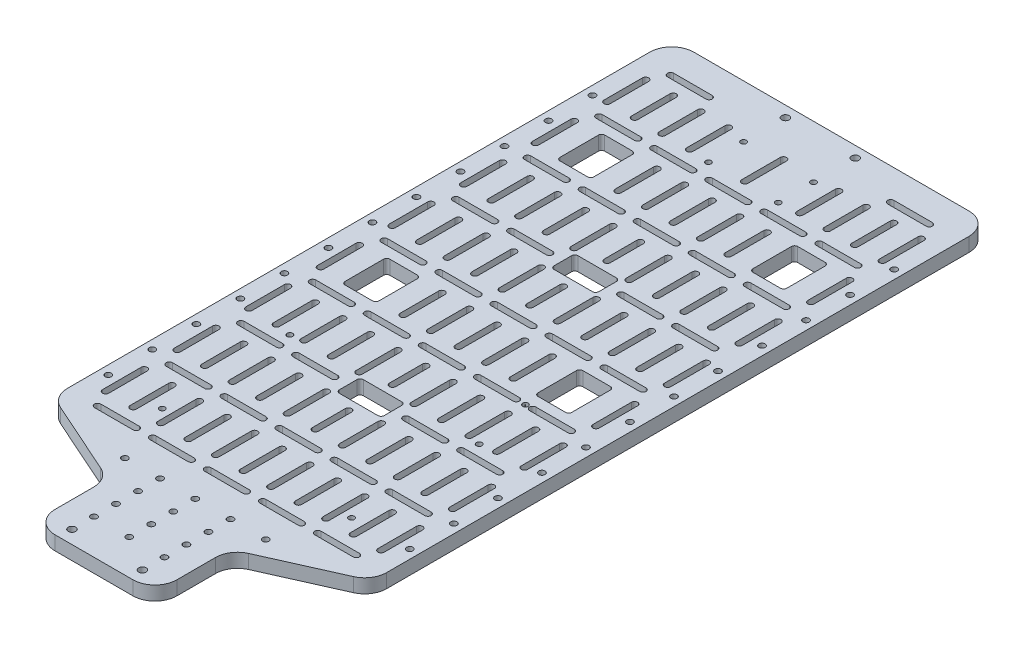
from build123d import *

# Parameters (mm, degrees)
SKETCH1_W           = 145
SKETCH1_H           = 335
BOSS_EXTRUDE1_DEPTH = 6.35
SKETCH2_R           = 1.7
SKETCH2_R_2         = 1.4224
SKETCH2_R_3         = 1.27
SKETCH2_R_4         = 0.056
CUT_EXTRUDE1_DEPTH  = 7.35
FILLET1_R           = 10


with BuildPart() as part:
    # Sketch1 → Boss-Extrude1 (new body)
    with BuildSketch(Plane(origin=(0, 0, 0), x_dir=(1, 0, 0), z_dir=(0, 1, 0))):
        with Locations((0, -167.5)):
            Rectangle(SKETCH1_W, SKETCH1_H)
    extrude(amount=BOSS_EXTRUDE1_DEPTH)

    # Sketch2 → Cut-Extrude1 (cut, through all)
    with BuildSketch(Plane(origin=(0, 6.35, 0), x_dir=(1, 0, 0), z_dir=(0, 1, 0))):
        with Locations((-15.875, -5)):
            Circle(SKETCH2_R)
        with Locations((-16, -329)):
            Circle(SKETCH2_R)
        with Locations((-68.497571427, -240)):
            Circle(SKETCH2_R_2)
        with Locations((68.497571427, -240)):
            Circle(SKETCH2_R_2)
        with Locations((-68.497571427, -220)):
            Circle(SKETCH2_R_2)
        with Locations((-68.497571427, -200)):
            Circle(SKETCH2_R_2)
        with Locations((-68.497571427, -180)):
            Circle(SKETCH2_R_2)
        with Locations((-68.497571427, -160)):
            Circle(SKETCH2_R_2)
        with Locations((-68.497571427, -140)):
            Circle(SKETCH2_R_2)
        with Locations((-68.497571427, -120)):
            Circle(SKETCH2_R_2)
        with Locations((-68.497571427, -100)):
            Circle(SKETCH2_R_2)
        with Locations((-68.497571427, -80)):
            Circle(SKETCH2_R_2)
        with Locations((-68.497571427, -60)):
            Circle(SKETCH2_R_2)
        with Locations((-68.497571427, -40)):
            Circle(SKETCH2_R_2)
        with Locations((-68.497571427, -260)):
            Circle(SKETCH2_R_2)
        with Locations((68.497571427, -40)):
            Circle(SKETCH2_R_2)
        with Locations((68.497571427, -60)):
            Circle(SKETCH2_R_2)
        with Locations((68.497571427, -80)):
            Circle(SKETCH2_R_2)
        with Locations((68.497571427, -100)):
            Circle(SKETCH2_R_2)
        with Locations((68.497571427, -120)):
            Circle(SKETCH2_R_2)
        with Locations((68.497571427, -140)):
            Circle(SKETCH2_R_2)
        with Locations((68.497571427, -160)):
            Circle(SKETCH2_R_2)
        with Locations((68.497571427, -180)):
            Circle(SKETCH2_R_2)
        with Locations((68.497571427, -200)):
            Circle(SKETCH2_R_2)
        with Locations((68.497571427, -220)):
            Circle(SKETCH2_R_2)
        with Locations((68.497571427, -260)):
            Circle(SKETCH2_R_2)
        with Locations((16, -329)):
            Circle(SKETCH2_R)
        with Locations((15.875, -5)):
            Circle(SKETCH2_R)
        with Locations((-15.875, -40)):
            Circle(SKETCH2_R_3)
        with Locations((-15.875, -24)):
            Circle(SKETCH2_R_3)
        with Locations((15.875, -40)):
            Circle(SKETCH2_R_3)
        with Locations((15.875, -24)):
            Circle(SKETCH2_R_3)
        with Locations((-43, -261)):
            Circle(SKETCH2_R_3)
        with Locations((-43, -203)):
            Circle(SKETCH2_R_3)
        with Locations((43, -261)):
            Circle(SKETCH2_R_3)
        with Locations((43, -203)):
            Circle(SKETCH2_R_3)
        with Locations((0, -319)):
            Circle(SKETCH2_R_2)
        with Locations((16, -319)):
            Circle(SKETCH2_R_2)
        with Locations((-16, -319)):
            Circle(SKETCH2_R_2)
        with Locations((-16, -309)):
            Circle(SKETCH2_R_2)
        with Locations((0, -309)):
            Circle(SKETCH2_R_2)
        with Locations((16, -309)):
            Circle(SKETCH2_R_2)
        with Locations((-16, -299)):
            Circle(SKETCH2_R_2)
        with Locations((0, -299)):
            Circle(SKETCH2_R_2)
        with Locations((16, -299)):
            Circle(SKETCH2_R_2)
        with Locations((-16, -289)):
            Circle(SKETCH2_R_2)
        with Locations((0, -289)):
            Circle(SKETCH2_R_2)
        with Locations((16, -289)):
            Circle(SKETCH2_R_2)
        with Locations((-32, -289)):
            Circle(SKETCH2_R_2)
        with Locations((32, -289)):
            Circle(SKETCH2_R_2)
        with Locations((37.99, -176.997713648)):
            Circle(SKETCH2_R_3)
        with Locations((37.99, -176.997713648)):
            Circle(SKETCH2_R_4, mode=Mode.SUBTRACT)
        Polygon((-27.685, -301), (-72.5, -281), (-72.5, -335), (-27.685, -335), align=None)
        with BuildLine():
            Line((16.25, -273.1552), (33.75, -273.1552))
            ThreePointArc((33.75, -273.1552), (35.1724, -274.5776), (33.75, -276))
            Line((33.75, -276), (16.25, -276))
            ThreePointArc((16.25, -276), (14.8276, -274.5776), (16.25, -273.1552))
        make_face()
        with BuildLine():
            Line((-8.75, -273.1552), (8.75, -273.1552))
            ThreePointArc((8.75, -273.1552), (10.1724, -274.5776), (8.75, -276))
            Line((8.75, -276), (-8.75, -276))
            ThreePointArc((-8.75, -276), (-10.1724, -274.5776), (-8.75, -273.1552))
        make_face()
        with BuildLine():
            Line((41.25, -273.1552), (58.75, -273.1552))
            ThreePointArc((58.75, -273.1552), (60.1724, -274.5776), (58.75, -276))
            Line((58.75, -276), (41.25, -276))
            ThreePointArc((41.25, -276), (39.8276, -274.5776), (41.25, -273.1552))
        make_face()
        with BuildLine():
            Line((-33.75, -273.1552), (-16.25, -273.1552))
            ThreePointArc((-16.25, -273.1552), (-14.8276, -274.5776), (-16.25, -276))
            Line((-16.25, -276), (-33.75, -276))
            ThreePointArc((-33.75, -276), (-35.1724, -274.5776), (-33.75, -273.1552))
        make_face()
        with BuildLine():
            Line((-58.75, -273.1552), (-41.25, -273.1552))
            ThreePointArc((-41.25, -273.1552), (-39.8276, -274.5776), (-41.25, -276))
            Line((-41.25, -276), (-58.75, -276))
            ThreePointArc((-58.75, -276), (-60.1724, -274.5776), (-58.75, -273.1552))
        make_face()
        with BuildLine():
            Line((-1.4224, -249.5776), (-1.4224, -267.0776))
            ThreePointArc((-1.4224, -267.0776), (0, -268.5), (1.4224, -267.0776))
            Line((1.4224, -267.0776), (1.4224, -249.5776))
            ThreePointArc((1.4224, -249.5776), (0, -248.1552), (-1.4224, -249.5776))
        make_face()
        with BuildLine():
            Line((13.9224, -249.5776), (13.9224, -267.0776))
            ThreePointArc((13.9224, -267.0776), (12.5, -268.5), (11.0776, -267.0776))
            Line((11.0776, -267.0776), (11.0776, -249.5776))
            ThreePointArc((11.0776, -249.5776), (12.5, -248.1552), (13.9224, -249.5776))
        make_face()
        with BuildLine():
            Line((26.4224, -249.5776), (26.4224, -267.0776))
            ThreePointArc((26.4224, -267.0776), (25, -268.5), (23.5776, -267.0776))
            Line((23.5776, -267.0776), (23.5776, -249.5776))
            ThreePointArc((23.5776, -249.5776), (25, -248.1552), (26.4224, -249.5776))
        make_face()
        with BuildLine():
            Line((38.9224, -249.5776), (38.9224, -267.0776))
            ThreePointArc((38.9224, -267.0776), (37.5, -268.5), (36.0776, -267.0776))
            Line((36.0776, -267.0776), (36.0776, -249.5776))
            ThreePointArc((36.0776, -249.5776), (37.5, -248.1552), (38.9224, -249.5776))
        make_face()
        with BuildLine():
            Line((51.4224, -249.5776), (51.4224, -267.0776))
            ThreePointArc((51.4224, -267.0776), (50, -268.5), (48.5776, -267.0776))
            Line((48.5776, -267.0776), (48.5776, -249.5776))
            ThreePointArc((48.5776, -249.5776), (50, -248.1552), (51.4224, -249.5776))
        make_face()
        with BuildLine():
            Line((63.9224, -249.5776), (63.9224, -267.0776))
            ThreePointArc((63.9224, -267.0776), (62.5, -268.5), (61.0776, -267.0776))
            Line((61.0776, -267.0776), (61.0776, -249.5776))
            ThreePointArc((61.0776, -249.5776), (62.5, -248.1552), (63.9224, -249.5776))
        make_face()
        with BuildLine():
            Line((-11.100678857, -249.5776), (-11.100678857, -267.0776))
            ThreePointArc((-11.100678857, -267.0776), (-12.523078857, -268.5), (-13.945478857, -267.0776))
            Line((-13.945478857, -267.0776), (-13.945478857, -249.5776))
            ThreePointArc((-13.945478857, -249.5776), (-12.523078857, -248.1552), (-11.100678857, -249.5776))
        make_face()
        with BuildLine():
            Line((-23.623757713, -249.5776), (-23.623757713, -267.0776))
            ThreePointArc((-23.623757713, -267.0776), (-25.046157713, -268.5), (-26.468557713, -267.0776))
            Line((-26.468557713, -267.0776), (-26.468557713, -249.5776))
            ThreePointArc((-26.468557713, -249.5776), (-25.046157713, -248.1552), (-23.623757713, -249.5776))
        make_face()
        with BuildLine():
            Line((-36.14683657, -249.5776), (-36.14683657, -267.0776))
            ThreePointArc((-36.14683657, -267.0776), (-37.56923657, -268.5), (-38.99163657, -267.0776))
            Line((-38.99163657, -267.0776), (-38.99163657, -249.5776))
            ThreePointArc((-38.99163657, -249.5776), (-37.56923657, -248.1552), (-36.14683657, -249.5776))
        make_face()
        with BuildLine():
            Line((-48.669915427, -249.5776), (-48.669915427, -267.0776))
            ThreePointArc((-48.669915427, -267.0776), (-50.092315427, -268.5), (-51.514715427, -267.0776))
            Line((-51.514715427, -267.0776), (-51.514715427, -249.5776))
            ThreePointArc((-51.514715427, -249.5776), (-50.092315427, -248.1552), (-48.669915427, -249.5776))
        make_face()
        with BuildLine():
            Line((-61.192994284, -249.5776), (-61.192994284, -267.0776))
            ThreePointArc((-61.192994284, -267.0776), (-62.615394284, -268.5), (-64.037794284, -267.0776))
            Line((-64.037794284, -267.0776), (-64.037794284, -249.5776))
            ThreePointArc((-64.037794284, -249.5776), (-62.615394284, -248.1552), (-61.192994284, -249.5776))
        make_face()
        with BuildLine():
            Line((-58.75, -240.606477969), (-41.25, -240.606477969))
            ThreePointArc((-41.25, -240.606477969), (-39.8276, -242.028877969), (-41.25, -243.451277969))
            Line((-41.25, -243.451277969), (-58.75, -243.451277969))
            ThreePointArc((-58.75, -243.451277969), (-60.1724, -242.028877969), (-58.75, -240.606477969))
        make_face()
        with BuildLine():
            Line((-61.192994284, -217.028877969), (-61.192994284, -234.528877969))
            ThreePointArc((-61.192994284, -234.528877969), (-62.615394284, -235.951277969), (-64.037794284, -234.528877969))
            Line((-64.037794284, -234.528877969), (-64.037794284, -217.028877969))
            ThreePointArc((-64.037794284, -217.028877969), (-62.615394284, -215.606477969), (-61.192994284, -217.028877969))
        make_face()
        with BuildLine():
            Line((-48.669915427, -217.028877969), (-48.669915427, -234.528877969))
            ThreePointArc((-48.669915427, -234.528877969), (-50.092315427, -235.951277969), (-51.514715427, -234.528877969))
            Line((-51.514715427, -234.528877969), (-51.514715427, -217.028877969))
            ThreePointArc((-51.514715427, -217.028877969), (-50.092315427, -215.606477969), (-48.669915427, -217.028877969))
        make_face()
        with BuildLine():
            Line((-36.14683657, -217.028877969), (-36.14683657, -234.528877969))
            ThreePointArc((-36.14683657, -234.528877969), (-37.56923657, -235.951277969), (-38.99163657, -234.528877969))
            Line((-38.99163657, -234.528877969), (-38.99163657, -217.028877969))
            ThreePointArc((-38.99163657, -217.028877969), (-37.56923657, -215.606477969), (-36.14683657, -217.028877969))
        make_face()
        with BuildLine():
            Line((-23.623757713, -217.028877969), (-23.623757713, -234.528877969))
            ThreePointArc((-23.623757713, -234.528877969), (-25.046157713, -235.951277969), (-26.468557713, -234.528877969))
            Line((-26.468557713, -234.528877969), (-26.468557713, -217.028877969))
            ThreePointArc((-26.468557713, -217.028877969), (-25.046157713, -215.606477969), (-23.623757713, -217.028877969))
        make_face()
        with BuildLine():
            Line((-11.100678857, -217.028877969), (-11.100678857, -234.528877969))
            ThreePointArc((-11.100678857, -234.528877969), (-12.523078857, -235.951277969), (-13.945478857, -234.528877969))
            Line((-13.945478857, -234.528877969), (-13.945478857, -217.028877969))
            ThreePointArc((-13.945478857, -217.028877969), (-12.523078857, -215.606477969), (-11.100678857, -217.028877969))
        make_face()
        with BuildLine():
            Line((-33.75, -240.606477969), (-16.25, -240.606477969))
            ThreePointArc((-16.25, -240.606477969), (-14.8276, -242.028877969), (-16.25, -243.451277969))
            Line((-16.25, -243.451277969), (-33.75, -243.451277969))
            ThreePointArc((-33.75, -243.451277969), (-35.1724, -242.028877969), (-33.75, -240.606477969))
        make_face()
        with BuildLine():
            Line((13.9224, -217.028877969), (13.9224, -234.528877969))
            ThreePointArc((13.9224, -234.528877969), (12.5, -235.951277969), (11.0776, -234.528877969))
            Line((11.0776, -234.528877969), (11.0776, -217.028877969))
            ThreePointArc((11.0776, -217.028877969), (12.5, -215.606477969), (13.9224, -217.028877969))
        make_face()
        with BuildLine():
            Line((26.4224, -217.028877969), (26.4224, -234.528877969))
            ThreePointArc((26.4224, -234.528877969), (25, -235.951277969), (23.5776, -234.528877969))
            Line((23.5776, -234.528877969), (23.5776, -217.028877969))
            ThreePointArc((23.5776, -217.028877969), (25, -215.606477969), (26.4224, -217.028877969))
        make_face()
        with BuildLine():
            Line((16.25, -240.606477969), (33.75, -240.606477969))
            ThreePointArc((33.75, -240.606477969), (35.1724, -242.028877969), (33.75, -243.451277969))
            Line((33.75, -243.451277969), (16.25, -243.451277969))
            ThreePointArc((16.25, -243.451277969), (14.8276, -242.028877969), (16.25, -240.606477969))
        make_face()
        with BuildLine():
            Line((-8.75, -240.606477969), (8.75, -240.606477969))
            ThreePointArc((8.75, -240.606477969), (10.1724, -242.028877969), (8.75, -243.451277969))
            Line((8.75, -243.451277969), (-8.75, -243.451277969))
            ThreePointArc((-8.75, -243.451277969), (-10.1724, -242.028877969), (-8.75, -240.606477969))
        make_face()
        with BuildLine():
            Line((38.9224, -217.028877969), (38.9224, -234.528877969))
            ThreePointArc((38.9224, -234.528877969), (37.5, -235.951277969), (36.0776, -234.528877969))
            Line((36.0776, -234.528877969), (36.0776, -217.028877969))
            ThreePointArc((36.0776, -217.028877969), (37.5, -215.606477969), (38.9224, -217.028877969))
        make_face()
        with BuildLine():
            Line((51.4224, -217.028877969), (51.4224, -234.528877969))
            ThreePointArc((51.4224, -234.528877969), (50, -235.951277969), (48.5776, -234.528877969))
            Line((48.5776, -234.528877969), (48.5776, -217.028877969))
            ThreePointArc((48.5776, -217.028877969), (50, -215.606477969), (51.4224, -217.028877969))
        make_face()
        with BuildLine():
            Line((41.25, -240.606477969), (58.75, -240.606477969))
            ThreePointArc((58.75, -240.606477969), (60.1724, -242.028877969), (58.75, -243.451277969))
            Line((58.75, -243.451277969), (41.25, -243.451277969))
            ThreePointArc((41.25, -243.451277969), (39.8276, -242.028877969), (41.25, -240.606477969))
        make_face()
        with BuildLine():
            Line((63.9224, -217.028877969), (63.9224, -234.528877969))
            ThreePointArc((63.9224, -234.528877969), (62.5, -235.951277969), (61.0776, -234.528877969))
            Line((61.0776, -234.528877969), (61.0776, -217.028877969))
            ThreePointArc((61.0776, -217.028877969), (62.5, -215.606477969), (63.9224, -217.028877969))
        make_face()
        with BuildLine():
            Line((-58.75, -208.057755938), (-41.25, -208.057755938))
            ThreePointArc((-41.25, -208.057755938), (-39.8276, -209.480155938), (-41.25, -210.902555938))
            Line((-41.25, -210.902555938), (-58.75, -210.902555938))
            ThreePointArc((-58.75, -210.902555938), (-60.1724, -209.480155938), (-58.75, -208.057755938))
        make_face()
        with BuildLine():
            Line((-61.192994284, -184.480155938), (-61.192994284, -201.980155938))
            ThreePointArc((-61.192994284, -201.980155938), (-62.615394284, -203.402555938), (-64.037794284, -201.980155938))
            Line((-64.037794284, -201.980155938), (-64.037794284, -184.480155938))
            ThreePointArc((-64.037794284, -184.480155938), (-62.615394284, -183.057755938), (-61.192994284, -184.480155938))
        make_face()
        with BuildLine():
            Line((-48.669915427, -184.480155938), (-48.669915427, -201.980155938))
            ThreePointArc((-48.669915427, -201.980155938), (-50.092315427, -203.402555938), (-51.514715427, -201.980155938))
            Line((-51.514715427, -201.980155938), (-51.514715427, -184.480155938))
            ThreePointArc((-51.514715427, -184.480155938), (-50.092315427, -183.057755938), (-48.669915427, -184.480155938))
        make_face()
        with BuildLine():
            Line((-36.14683657, -184.480155938), (-36.14683657, -201.980155938))
            ThreePointArc((-36.14683657, -201.980155938), (-37.56923657, -203.402555938), (-38.99163657, -201.980155938))
            Line((-38.99163657, -201.980155938), (-38.99163657, -184.480155938))
            ThreePointArc((-38.99163657, -184.480155938), (-37.56923657, -183.057755938), (-36.14683657, -184.480155938))
        make_face()
        with BuildLine():
            Line((-23.623757713, -184.480155938), (-23.623757713, -201.980155938))
            ThreePointArc((-23.623757713, -201.980155938), (-25.046157713, -203.402555938), (-26.468557713, -201.980155938))
            Line((-26.468557713, -201.980155938), (-26.468557713, -184.480155938))
            ThreePointArc((-26.468557713, -184.480155938), (-25.046157713, -183.057755938), (-23.623757713, -184.480155938))
        make_face()
        with BuildLine():
            Line((-11.100678857, -184.480155938), (-11.100678857, -201.980155938))
            ThreePointArc((-11.100678857, -201.980155938), (-12.523078857, -203.402555938), (-13.945478857, -201.980155938))
            Line((-13.945478857, -201.980155938), (-13.945478857, -184.480155938))
            ThreePointArc((-13.945478857, -184.480155938), (-12.523078857, -183.057755938), (-11.100678857, -184.480155938))
        make_face()
        with BuildLine():
            Line((-33.75, -208.057755938), (-16.25, -208.057755938))
            ThreePointArc((-16.25, -208.057755938), (-14.8276, -209.480155938), (-16.25, -210.902555938))
            Line((-16.25, -210.902555938), (-33.75, -210.902555938))
            ThreePointArc((-33.75, -210.902555938), (-35.1724, -209.480155938), (-33.75, -208.057755938))
        make_face()
        with BuildLine():
            Line((13.9224, -184.480155938), (13.9224, -201.980155938))
            ThreePointArc((13.9224, -201.980155938), (12.5, -203.402555938), (11.0776, -201.980155938))
            Line((11.0776, -201.980155938), (11.0776, -184.480155938))
            ThreePointArc((11.0776, -184.480155938), (12.5, -183.057755938), (13.9224, -184.480155938))
        make_face()
        with BuildLine():
            Line((26.4224, -184.480155938), (26.4224, -201.980155938))
            ThreePointArc((26.4224, -201.980155938), (25, -203.402555938), (23.5776, -201.980155938))
            Line((23.5776, -201.980155938), (23.5776, -184.480155938))
            ThreePointArc((23.5776, -184.480155938), (25, -183.057755938), (26.4224, -184.480155938))
        make_face()
        with BuildLine():
            Line((16.25, -208.057755938), (33.75, -208.057755938))
            ThreePointArc((33.75, -208.057755938), (35.1724, -209.480155938), (33.75, -210.902555938))
            Line((33.75, -210.902555938), (16.25, -210.902555938))
            ThreePointArc((16.25, -210.902555938), (14.8276, -209.480155938), (16.25, -208.057755938))
        make_face()
        with BuildLine():
            Line((38.9224, -184.480155938), (38.9224, -201.980155938))
            ThreePointArc((38.9224, -201.980155938), (37.5, -203.402555938), (36.0776, -201.980155938))
            Line((36.0776, -201.980155938), (36.0776, -184.480155938))
            ThreePointArc((36.0776, -184.480155938), (37.5, -183.057755938), (38.9224, -184.480155938))
        make_face()
        with BuildLine():
            Line((51.4224, -184.480155938), (51.4224, -201.980155938))
            ThreePointArc((51.4224, -201.980155938), (50, -203.402555938), (48.5776, -201.980155938))
            Line((48.5776, -201.980155938), (48.5776, -184.480155938))
            ThreePointArc((48.5776, -184.480155938), (50, -183.057755938), (51.4224, -184.480155938))
        make_face()
        with BuildLine():
            Line((41.25, -208.057755938), (58.75, -208.057755938))
            ThreePointArc((58.75, -208.057755938), (60.1724, -209.480155938), (58.75, -210.902555938))
            Line((58.75, -210.902555938), (41.25, -210.902555938))
            ThreePointArc((41.25, -210.902555938), (39.8276, -209.480155938), (41.25, -208.057755938))
        make_face()
        with BuildLine():
            Line((63.9224, -184.480155938), (63.9224, -201.980155938))
            ThreePointArc((63.9224, -201.980155938), (62.5, -203.402555938), (61.0776, -201.980155938))
            Line((61.0776, -201.980155938), (61.0776, -184.480155938))
            ThreePointArc((61.0776, -184.480155938), (62.5, -183.057755938), (63.9224, -184.480155938))
        make_face()
        with BuildLine():
            Line((-58.75, -175.509033907), (-41.25, -175.509033907))
            ThreePointArc((-41.25, -175.509033907), (-39.8276, -176.931433907), (-41.25, -178.353833907))
            Line((-41.25, -178.353833907), (-58.75, -178.353833907))
            ThreePointArc((-58.75, -178.353833907), (-60.1724, -176.931433907), (-58.75, -175.509033907))
        make_face()
        with BuildLine():
            Line((-61.192994284, -151.931433907), (-61.192994284, -169.431433907))
            ThreePointArc((-61.192994284, -169.431433907), (-62.615394284, -170.853833907), (-64.037794284, -169.431433907))
            Line((-64.037794284, -169.431433907), (-64.037794284, -151.931433907))
            ThreePointArc((-64.037794284, -151.931433907), (-62.615394284, -150.509033907), (-61.192994284, -151.931433907))
        make_face()
        with BuildLine():
            Line((-51.514715427, -151.931433907), (-51.514715427, -169.431433907))
            ThreePointArc((-51.514715427, -169.431433907), (-51.098104113, -170.437222593), (-50.092315427, -170.853833907))
            Line((-50.092315427, -170.853833907), (-37.56923657, -170.853833907))
            ThreePointArc((-37.56923657, -170.853833907), (-36.563447885, -170.437222593), (-36.14683657, -169.431433907))
            Line((-36.14683657, -169.431433907), (-36.14683657, -151.931433907))
            ThreePointArc((-36.14683657, -151.931433907), (-36.563447885, -150.925645222), (-37.56923657, -150.509033907))
            Line((-37.56923657, -150.509033907), (-50.092315427, -150.509033907))
            ThreePointArc((-50.092315427, -150.509033907), (-51.098104113, -150.925645222), (-51.514715427, -151.931433907))
        make_face()
        with BuildLine():
            Line((-23.623757713, -151.931433907), (-23.623757713, -169.431433907))
            ThreePointArc((-23.623757713, -169.431433907), (-25.046157713, -170.853833907), (-26.468557713, -169.431433907))
            Line((-26.468557713, -169.431433907), (-26.468557713, -151.931433907))
            ThreePointArc((-26.468557713, -151.931433907), (-25.046157713, -150.509033907), (-23.623757713, -151.931433907))
        make_face()
        with BuildLine():
            Line((-11.100678857, -151.931433907), (-11.100678857, -169.431433907))
            ThreePointArc((-11.100678857, -169.431433907), (-12.523078857, -170.853833907), (-13.945478857, -169.431433907))
            Line((-13.945478857, -169.431433907), (-13.945478857, -151.931433907))
            ThreePointArc((-13.945478857, -151.931433907), (-12.523078857, -150.509033907), (-11.100678857, -151.931433907))
        make_face()
        with BuildLine():
            Line((-33.75, -175.509033907), (-16.25, -175.509033907))
            ThreePointArc((-16.25, -175.509033907), (-14.8276, -176.931433907), (-16.25, -178.353833907))
            Line((-16.25, -178.353833907), (-33.75, -178.353833907))
            ThreePointArc((-33.75, -178.353833907), (-35.1724, -176.931433907), (-33.75, -175.509033907))
        make_face()
        with BuildLine():
            Line((1.4224, -151.931433907), (1.4224, -169.431433907))
            ThreePointArc((1.4224, -169.431433907), (0, -170.853833907), (-1.4224, -169.431433907))
            Line((-1.4224, -169.431433907), (-1.4224, -151.931433907))
            ThreePointArc((-1.4224, -151.931433907), (0, -150.509033907), (1.4224, -151.931433907))
        make_face()
        with BuildLine():
            Line((13.9224, -151.931433907), (13.9224, -169.431433907))
            ThreePointArc((13.9224, -169.431433907), (12.5, -170.853833907), (11.0776, -169.431433907))
            Line((11.0776, -169.431433907), (11.0776, -151.931433907))
            ThreePointArc((11.0776, -151.931433907), (12.5, -150.509033907), (13.9224, -151.931433907))
        make_face()
        with BuildLine():
            Line((26.4224, -151.931433907), (26.4224, -169.431433907))
            ThreePointArc((26.4224, -169.431433907), (25, -170.853833907), (23.5776, -169.431433907))
            Line((23.5776, -169.431433907), (23.5776, -151.931433907))
            ThreePointArc((23.5776, -151.931433907), (25, -150.509033907), (26.4224, -151.931433907))
        make_face()
        with BuildLine():
            Line((16.25, -175.509033907), (33.75, -175.509033907))
            ThreePointArc((33.75, -175.509033907), (35.1724, -176.931433907), (33.75, -178.353833907))
            Line((33.75, -178.353833907), (16.25, -178.353833907))
            ThreePointArc((16.25, -178.353833907), (14.8276, -176.931433907), (16.25, -175.509033907))
        make_face()
        with BuildLine():
            Line((-8.75, -175.509033907), (8.75, -175.509033907))
            ThreePointArc((8.75, -175.509033907), (10.1724, -176.931433907), (8.75, -178.353833907))
            Line((8.75, -178.353833907), (-8.75, -178.353833907))
            ThreePointArc((-8.75, -178.353833907), (-10.1724, -176.931433907), (-8.75, -175.509033907))
        make_face()
        with BuildLine():
            Line((41.25, -175.509033907), (58.75, -175.509033907))
            ThreePointArc((58.75, -175.509033907), (60.1724, -176.931433907), (58.75, -178.353833907))
            Line((58.75, -178.353833907), (41.25, -178.353833907))
            ThreePointArc((41.25, -178.353833907), (39.8276, -176.931433907), (41.25, -175.509033907))
        make_face()
        with BuildLine():
            Line((63.9224, -151.931433907), (63.9224, -169.431433907))
            ThreePointArc((63.9224, -169.431433907), (62.5, -170.853833907), (61.0776, -169.431433907))
            Line((61.0776, -169.431433907), (61.0776, -151.931433907))
            ThreePointArc((61.0776, -151.931433907), (62.5, -150.509033907), (63.9224, -151.931433907))
        make_face()
        with BuildLine():
            Line((-58.75, -142.960311876), (-41.25, -142.960311876))
            ThreePointArc((-41.25, -142.960311876), (-39.8276, -144.382711876), (-41.25, -145.805111876))
            Line((-41.25, -145.805111876), (-58.75, -145.805111876))
            ThreePointArc((-58.75, -145.805111876), (-60.1724, -144.382711876), (-58.75, -142.960311876))
        make_face()
        with BuildLine():
            Line((-61.192994284, -119.382711876), (-61.192994284, -136.882711876))
            ThreePointArc((-61.192994284, -136.882711876), (-62.615394284, -138.305111876), (-64.037794284, -136.882711876))
            Line((-64.037794284, -136.882711876), (-64.037794284, -119.382711876))
            ThreePointArc((-64.037794284, -119.382711876), (-62.615394284, -117.960311876), (-61.192994284, -119.382711876))
        make_face()
        with BuildLine():
            Line((-48.669915427, -119.382711876), (-48.669915427, -136.882711876))
            ThreePointArc((-48.669915427, -136.882711876), (-50.092315427, -138.305111876), (-51.514715427, -136.882711876))
            Line((-51.514715427, -136.882711876), (-51.514715427, -119.382711876))
            ThreePointArc((-51.514715427, -119.382711876), (-50.092315427, -117.960311876), (-48.669915427, -119.382711876))
        make_face()
        with BuildLine():
            Line((-36.14683657, -119.382711876), (-36.14683657, -136.882711876))
            ThreePointArc((-36.14683657, -136.882711876), (-37.56923657, -138.305111876), (-38.99163657, -136.882711876))
            Line((-38.99163657, -136.882711876), (-38.99163657, -119.382711876))
            ThreePointArc((-38.99163657, -119.382711876), (-37.56923657, -117.960311876), (-36.14683657, -119.382711876))
        make_face()
        with BuildLine():
            Line((-23.623757713, -119.382711876), (-23.623757713, -136.882711876))
            ThreePointArc((-23.623757713, -136.882711876), (-25.046157713, -138.305111876), (-26.468557713, -136.882711876))
            Line((-26.468557713, -136.882711876), (-26.468557713, -119.382711876))
            ThreePointArc((-26.468557713, -119.382711876), (-25.046157713, -117.960311876), (-23.623757713, -119.382711876))
        make_face()
        with BuildLine():
            Line((-11.100678857, -119.382711876), (-11.100678857, -136.882711876))
            ThreePointArc((-11.100678857, -136.882711876), (-12.523078857, -138.305111876), (-13.945478857, -136.882711876))
            Line((-13.945478857, -136.882711876), (-13.945478857, -119.382711876))
            ThreePointArc((-13.945478857, -119.382711876), (-12.523078857, -117.960311876), (-11.100678857, -119.382711876))
        make_face()
        with BuildLine():
            Line((-33.75, -142.960311876), (-16.25, -142.960311876))
            ThreePointArc((-16.25, -142.960311876), (-14.8276, -144.382711876), (-16.25, -145.805111876))
            Line((-16.25, -145.805111876), (-33.75, -145.805111876))
            ThreePointArc((-33.75, -145.805111876), (-35.1724, -144.382711876), (-33.75, -142.960311876))
        make_face()
        with BuildLine():
            Line((13.9224, -119.382711876), (13.9224, -136.882711876))
            ThreePointArc((13.9224, -136.882711876), (12.5, -138.305111876), (11.0776, -136.882711876))
            Line((11.0776, -136.882711876), (11.0776, -119.382711876))
            ThreePointArc((11.0776, -119.382711876), (12.5, -117.960311876), (13.9224, -119.382711876))
        make_face()
        with BuildLine():
            Line((26.4224, -119.382711876), (26.4224, -136.882711876))
            ThreePointArc((26.4224, -136.882711876), (25, -138.305111876), (23.5776, -136.882711876))
            Line((23.5776, -136.882711876), (23.5776, -119.382711876))
            ThreePointArc((23.5776, -119.382711876), (25, -117.960311876), (26.4224, -119.382711876))
        make_face()
        with BuildLine():
            Line((16.25, -142.960311876), (33.75, -142.960311876))
            ThreePointArc((33.75, -142.960311876), (35.1724, -144.382711876), (33.75, -145.805111876))
            Line((33.75, -145.805111876), (16.25, -145.805111876))
            ThreePointArc((16.25, -145.805111876), (14.8276, -144.382711876), (16.25, -142.960311876))
        make_face()
        with BuildLine():
            Line((-8.75, -142.960311876), (8.75, -142.960311876))
            ThreePointArc((8.75, -142.960311876), (10.1724, -144.382711876), (8.75, -145.805111876))
            Line((8.75, -145.805111876), (-8.75, -145.805111876))
            ThreePointArc((-8.75, -145.805111876), (-10.1724, -144.382711876), (-8.75, -142.960311876))
        make_face()
        with BuildLine():
            Line((38.9224, -119.382711876), (38.9224, -136.882711876))
            ThreePointArc((38.9224, -136.882711876), (37.5, -138.305111876), (36.0776, -136.882711876))
            Line((36.0776, -136.882711876), (36.0776, -119.382711876))
            ThreePointArc((36.0776, -119.382711876), (37.5, -117.960311876), (38.9224, -119.382711876))
        make_face()
        with BuildLine():
            Line((51.4224, -119.382711876), (51.4224, -136.882711876))
            ThreePointArc((51.4224, -136.882711876), (50, -138.305111876), (48.5776, -136.882711876))
            Line((48.5776, -136.882711876), (48.5776, -119.382711876))
            ThreePointArc((48.5776, -119.382711876), (50, -117.960311876), (51.4224, -119.382711876))
        make_face()
        with BuildLine():
            Line((41.25, -142.960311876), (58.75, -142.960311876))
            ThreePointArc((58.75, -142.960311876), (60.1724, -144.382711876), (58.75, -145.805111876))
            Line((58.75, -145.805111876), (41.25, -145.805111876))
            ThreePointArc((41.25, -145.805111876), (39.8276, -144.382711876), (41.25, -142.960311876))
        make_face()
        with BuildLine():
            Line((63.9224, -119.382711876), (63.9224, -136.882711876))
            ThreePointArc((63.9224, -136.882711876), (62.5, -138.305111876), (61.0776, -136.882711876))
            Line((61.0776, -136.882711876), (61.0776, -119.382711876))
            ThreePointArc((61.0776, -119.382711876), (62.5, -117.960311876), (63.9224, -119.382711876))
        make_face()
        with BuildLine():
            Line((-58.75, -110.411589846), (-41.25, -110.411589846))
            ThreePointArc((-41.25, -110.411589846), (-39.8276, -111.833989846), (-41.25, -113.256389846))
            Line((-41.25, -113.256389846), (-58.75, -113.256389846))
            ThreePointArc((-58.75, -113.256389846), (-60.1724, -111.833989846), (-58.75, -110.411589846))
        make_face()
        with BuildLine():
            Line((-61.192994284, -86.833989846), (-61.192994284, -104.333989846))
            ThreePointArc((-61.192994284, -104.333989846), (-62.615394284, -105.756389846), (-64.037794284, -104.333989846))
            Line((-64.037794284, -104.333989846), (-64.037794284, -86.833989846))
            ThreePointArc((-64.037794284, -86.833989846), (-62.615394284, -85.411589846), (-61.192994284, -86.833989846))
        make_face()
        with BuildLine():
            Line((-48.669915427, -86.833989846), (-48.669915427, -104.333989846))
            ThreePointArc((-48.669915427, -104.333989846), (-50.092315427, -105.756389846), (-51.514715427, -104.333989846))
            Line((-51.514715427, -104.333989846), (-51.514715427, -86.833989846))
            ThreePointArc((-51.514715427, -86.833989846), (-50.092315427, -85.411589846), (-48.669915427, -86.833989846))
        make_face()
        with BuildLine():
            Line((-36.14683657, -86.833989846), (-36.14683657, -104.333989846))
            ThreePointArc((-36.14683657, -104.333989846), (-37.56923657, -105.756389846), (-38.99163657, -104.333989846))
            Line((-38.99163657, -104.333989846), (-38.99163657, -86.833989846))
            ThreePointArc((-38.99163657, -86.833989846), (-37.56923657, -85.411589846), (-36.14683657, -86.833989846))
        make_face()
        with BuildLine():
            Line((-23.623757713, -86.833989846), (-23.623757713, -104.333989846))
            ThreePointArc((-23.623757713, -104.333989846), (-25.046157713, -105.756389846), (-26.468557713, -104.333989846))
            Line((-26.468557713, -104.333989846), (-26.468557713, -86.833989846))
            ThreePointArc((-26.468557713, -86.833989846), (-25.046157713, -85.411589846), (-23.623757713, -86.833989846))
        make_face()
        with BuildLine():
            Line((-11.100678857, -86.833989846), (-11.100678857, -104.333989846))
            ThreePointArc((-11.100678857, -104.333989846), (-12.523078857, -105.756389846), (-13.945478857, -104.333989846))
            Line((-13.945478857, -104.333989846), (-13.945478857, -86.833989846))
            ThreePointArc((-13.945478857, -86.833989846), (-12.523078857, -85.411589846), (-11.100678857, -86.833989846))
        make_face()
        with BuildLine():
            Line((-33.75, -110.411589846), (-16.25, -110.411589846))
            ThreePointArc((-16.25, -110.411589846), (-14.8276, -111.833989846), (-16.25, -113.256389846))
            Line((-16.25, -113.256389846), (-33.75, -113.256389846))
            ThreePointArc((-33.75, -113.256389846), (-35.1724, -111.833989846), (-33.75, -110.411589846))
        make_face()
        with BuildLine():
            Line((13.9224, -86.833989846), (13.9224, -104.333989846))
            ThreePointArc((13.9224, -104.333989846), (12.5, -105.756389846), (11.0776, -104.333989846))
            Line((11.0776, -104.333989846), (11.0776, -86.833989846))
            ThreePointArc((11.0776, -86.833989846), (12.5, -85.411589846), (13.9224, -86.833989846))
        make_face()
        with BuildLine():
            Line((26.4224, -86.833989846), (26.4224, -104.333989846))
            ThreePointArc((26.4224, -104.333989846), (25, -105.756389846), (23.5776, -104.333989846))
            Line((23.5776, -104.333989846), (23.5776, -86.833989846))
            ThreePointArc((23.5776, -86.833989846), (25, -85.411589846), (26.4224, -86.833989846))
        make_face()
        with BuildLine():
            Line((16.25, -110.411589846), (33.75, -110.411589846))
            ThreePointArc((33.75, -110.411589846), (35.1724, -111.833989846), (33.75, -113.256389846))
            Line((33.75, -113.256389846), (16.25, -113.256389846))
            ThreePointArc((16.25, -113.256389846), (14.8276, -111.833989846), (16.25, -110.411589846))
        make_face()
        with BuildLine():
            Line((38.9224, -86.833989846), (38.9224, -104.333989846))
            ThreePointArc((38.9224, -104.333989846), (37.5, -105.756389846), (36.0776, -104.333989846))
            Line((36.0776, -104.333989846), (36.0776, -86.833989846))
            ThreePointArc((36.0776, -86.833989846), (37.5, -85.411589846), (38.9224, -86.833989846))
        make_face()
        with BuildLine():
            Line((51.4224, -86.833989846), (51.4224, -104.333989846))
            ThreePointArc((51.4224, -104.333989846), (50, -105.756389846), (48.5776, -104.333989846))
            Line((48.5776, -104.333989846), (48.5776, -86.833989846))
            ThreePointArc((48.5776, -86.833989846), (50, -85.411589846), (51.4224, -86.833989846))
        make_face()
        with BuildLine():
            Line((41.25, -110.411589846), (58.75, -110.411589846))
            ThreePointArc((58.75, -110.411589846), (60.1724, -111.833989846), (58.75, -113.256389846))
            Line((58.75, -113.256389846), (41.25, -113.256389846))
            ThreePointArc((41.25, -113.256389846), (39.8276, -111.833989846), (41.25, -110.411589846))
        make_face()
        with BuildLine():
            Line((63.9224, -86.833989846), (63.9224, -104.333989846))
            ThreePointArc((63.9224, -104.333989846), (62.5, -105.756389846), (61.0776, -104.333989846))
            Line((61.0776, -104.333989846), (61.0776, -86.833989846))
            ThreePointArc((61.0776, -86.833989846), (62.5, -85.411589846), (63.9224, -86.833989846))
        make_face()
        with BuildLine():
            Line((-58.75, -77.862867815), (-41.25, -77.862867815))
            ThreePointArc((-41.25, -77.862867815), (-39.8276, -79.285267815), (-41.25, -80.707667815))
            Line((-41.25, -80.707667815), (-58.75, -80.707667815))
            ThreePointArc((-58.75, -80.707667815), (-60.1724, -79.285267815), (-58.75, -77.862867815))
        make_face()
        with BuildLine():
            Line((-61.192994284, -54.285267815), (-61.192994284, -71.785267815))
            ThreePointArc((-61.192994284, -71.785267815), (-62.615394284, -73.207667815), (-64.037794284, -71.785267815))
            Line((-64.037794284, -71.785267815), (-64.037794284, -54.285267815))
            ThreePointArc((-64.037794284, -54.285267815), (-62.615394284, -52.862867815), (-61.192994284, -54.285267815))
        make_face()
        with BuildLine():
            Line((-51.514715427, -54.285267815), (-51.514715427, -71.785267815))
            ThreePointArc((-51.514715427, -71.785267815), (-51.098104113, -72.7910565), (-50.092315427, -73.207667815))
            Line((-50.092315427, -73.207667815), (-37.56923657, -73.207667815))
            ThreePointArc((-37.56923657, -73.207667815), (-36.563447885, -72.7910565), (-36.14683657, -71.785267815))
            Line((-36.14683657, -71.785267815), (-36.14683657, -54.285267815))
            ThreePointArc((-36.14683657, -54.285267815), (-36.563447885, -53.279479129), (-37.56923657, -52.862867815))
            Line((-37.56923657, -52.862867815), (-50.092315427, -52.862867815))
            ThreePointArc((-50.092315427, -52.862867815), (-51.098104113, -53.279479129), (-51.514715427, -54.285267815))
        make_face()
        with BuildLine():
            Line((-23.623757713, -54.285267815), (-23.623757713, -71.785267815))
            ThreePointArc((-23.623757713, -71.785267815), (-25.046157713, -73.207667815), (-26.468557713, -71.785267815))
            Line((-26.468557713, -71.785267815), (-26.468557713, -54.285267815))
            ThreePointArc((-26.468557713, -54.285267815), (-25.046157713, -52.862867815), (-23.623757713, -54.285267815))
        make_face()
        with BuildLine():
            Line((-11.100678857, -54.285267815), (-11.100678857, -71.785267815))
            ThreePointArc((-11.100678857, -71.785267815), (-12.523078857, -73.207667815), (-13.945478857, -71.785267815))
            Line((-13.945478857, -71.785267815), (-13.945478857, -54.285267815))
            ThreePointArc((-13.945478857, -54.285267815), (-12.523078857, -52.862867815), (-11.100678857, -54.285267815))
        make_face()
        with BuildLine():
            Line((-33.75, -77.862867815), (-16.25, -77.862867815))
            ThreePointArc((-16.25, -77.862867815), (-14.8276, -79.285267815), (-16.25, -80.707667815))
            Line((-16.25, -80.707667815), (-33.75, -80.707667815))
            ThreePointArc((-33.75, -80.707667815), (-35.1724, -79.285267815), (-33.75, -77.862867815))
        make_face()
        with BuildLine():
            Line((1.4224, -54.285267815), (1.4224, -71.785267815))
            ThreePointArc((1.4224, -71.785267815), (0, -73.207667815), (-1.4224, -71.785267815))
            Line((-1.4224, -71.785267815), (-1.4224, -54.285267815))
            ThreePointArc((-1.4224, -54.285267815), (0, -52.862867815), (1.4224, -54.285267815))
        make_face()
        with BuildLine():
            Line((13.9224, -54.285267815), (13.9224, -71.785267815))
            ThreePointArc((13.9224, -71.785267815), (12.5, -73.207667815), (11.0776, -71.785267815))
            Line((11.0776, -71.785267815), (11.0776, -54.285267815))
            ThreePointArc((11.0776, -54.285267815), (12.5, -52.862867815), (13.9224, -54.285267815))
        make_face()
        with BuildLine():
            Line((26.4224, -54.285267815), (26.4224, -71.785267815))
            ThreePointArc((26.4224, -71.785267815), (25, -73.207667815), (23.5776, -71.785267815))
            Line((23.5776, -71.785267815), (23.5776, -54.285267815))
            ThreePointArc((23.5776, -54.285267815), (25, -52.862867815), (26.4224, -54.285267815))
        make_face()
        with BuildLine():
            Line((16.25, -77.862867815), (33.75, -77.862867815))
            ThreePointArc((33.75, -77.862867815), (35.1724, -79.285267815), (33.75, -80.707667815))
            Line((33.75, -80.707667815), (16.25, -80.707667815))
            ThreePointArc((16.25, -80.707667815), (14.8276, -79.285267815), (16.25, -77.862867815))
        make_face()
        with BuildLine():
            Line((-8.75, -77.862867815), (8.75, -77.862867815))
            ThreePointArc((8.75, -77.862867815), (10.1724, -79.285267815), (8.75, -80.707667815))
            Line((8.75, -80.707667815), (-8.75, -80.707667815))
            ThreePointArc((-8.75, -80.707667815), (-10.1724, -79.285267815), (-8.75, -77.862867815))
        make_face()
        with BuildLine():
            Line((41.25, -77.862867815), (58.75, -77.862867815))
            ThreePointArc((58.75, -77.862867815), (60.1724, -79.285267815), (58.75, -80.707667815))
            Line((58.75, -80.707667815), (41.25, -80.707667815))
            ThreePointArc((41.25, -80.707667815), (39.8276, -79.285267815), (41.25, -77.862867815))
        make_face()
        with BuildLine():
            Line((63.9224, -54.285267815), (63.9224, -71.785267815))
            ThreePointArc((63.9224, -71.785267815), (62.5, -73.207667815), (61.0776, -71.785267815))
            Line((61.0776, -71.785267815), (61.0776, -54.285267815))
            ThreePointArc((61.0776, -54.285267815), (62.5, -52.862867815), (63.9224, -54.285267815))
        make_face()
        with BuildLine():
            Line((-41.25, -48.207667815), (-58.75, -48.207667815))
            ThreePointArc((-58.75, -48.207667815), (-60.1724, -46.785267815), (-58.75, -45.362867815))
            Line((-58.75, -45.362867815), (-41.25, -45.362867815))
            ThreePointArc((-41.25, -45.362867815), (-39.8276, -46.785267815), (-41.25, -48.207667815))
        make_face()
        with BuildLine():
            Line((-33.75, -45.362867815), (-16.25, -45.362867815))
            ThreePointArc((-16.25, -45.362867815), (-14.8276, -46.785267815), (-16.25, -48.207667815))
            Line((-16.25, -48.207667815), (-33.75, -48.207667815))
            ThreePointArc((-33.75, -48.207667815), (-35.1724, -46.785267815), (-33.75, -45.362867815))
        make_face()
        with BuildLine():
            Line((-8.75, -45.362867815), (8.75, -45.362867815))
            ThreePointArc((8.75, -45.362867815), (10.1724, -46.785267815), (8.75, -48.207667815))
            Line((8.75, -48.207667815), (-8.75, -48.207667815))
            ThreePointArc((-8.75, -48.207667815), (-10.1724, -46.785267815), (-8.75, -45.362867815))
        make_face()
        with BuildLine():
            Line((16.25, -45.362867815), (33.75, -45.362867815))
            ThreePointArc((33.75, -45.362867815), (35.1724, -46.785267815), (33.75, -48.207667815))
            Line((33.75, -48.207667815), (16.25, -48.207667815))
            ThreePointArc((16.25, -48.207667815), (14.8276, -46.785267815), (16.25, -45.362867815))
        make_face()
        with BuildLine():
            Line((41.25, -45.362867815), (58.75, -45.362867815))
            ThreePointArc((58.75, -45.362867815), (60.1724, -46.785267815), (58.75, -48.207667815))
            Line((58.75, -48.207667815), (41.25, -48.207667815))
            ThreePointArc((41.25, -48.207667815), (39.8276, -46.785267815), (41.25, -45.362867815))
        make_face()
        Polygon((72.5, -281), (72.5, -335), (27.685, -335), (27.685, -301), align=None)
        with BuildLine():
            Line((-48.669915427, -21.785267815), (-48.669915427, -39.285267815))
            ThreePointArc((-48.669915427, -39.285267815), (-50.092315427, -40.707667815), (-51.514715427, -39.285267815))
            Line((-51.514715427, -39.285267815), (-51.514715427, -21.785267815))
            ThreePointArc((-51.514715427, -21.785267815), (-50.092315427, -20.362867815), (-48.669915427, -21.785267815))
        make_face()
        with BuildLine():
            Line((-36.14683657, -21.785267815), (-36.14683657, -39.285267815))
            ThreePointArc((-36.14683657, -39.285267815), (-37.56923657, -40.707667815), (-38.99163657, -39.285267815))
            Line((-38.99163657, -39.285267815), (-38.99163657, -21.785267815))
            ThreePointArc((-38.99163657, -21.785267815), (-37.56923657, -20.362867815), (-36.14683657, -21.785267815))
        make_face()
        with BuildLine():
            Line((51.4224, -21.785267815), (51.4224, -39.285267815))
            ThreePointArc((51.4224, -39.285267815), (50, -40.707667815), (48.5776, -39.285267815))
            Line((48.5776, -39.285267815), (48.5776, -21.785267815))
            ThreePointArc((48.5776, -21.785267815), (50, -20.362867815), (51.4224, -21.785267815))
        make_face()
        with BuildLine():
            Line((38.9224, -21.785267815), (38.9224, -39.285267815))
            ThreePointArc((38.9224, -39.285267815), (37.5, -40.707667815), (36.0776, -39.285267815))
            Line((36.0776, -39.285267815), (36.0776, -21.785267815))
            ThreePointArc((36.0776, -21.785267815), (37.5, -20.362867815), (38.9224, -21.785267815))
        make_face()
        with BuildLine():
            Line((63.9224, -21.785267815), (63.9224, -39.285267815))
            ThreePointArc((63.9224, -39.285267815), (62.5, -40.707667815), (61.0776, -39.285267815))
            Line((61.0776, -39.285267815), (61.0776, -21.785267815))
            ThreePointArc((61.0776, -21.785267815), (62.5, -20.362867815), (63.9224, -21.785267815))
        make_face()
        with BuildLine():
            Line((-61.192994284, -21.785267815), (-61.192994284, -39.285267815))
            ThreePointArc((-61.192994284, -39.285267815), (-62.615394284, -40.707667815), (-64.037794284, -39.285267815))
            Line((-64.037794284, -39.285267815), (-64.037794284, -21.785267815))
            ThreePointArc((-64.037794284, -21.785267815), (-62.615394284, -20.362867815), (-61.192994284, -21.785267815))
        make_face()
        with BuildLine():
            Line((-23.623757713, -21.785267815), (-23.623757713, -39.285267815))
            ThreePointArc((-23.623757713, -39.285267815), (-25.046157713, -40.707667815), (-26.468557713, -39.285267815))
            Line((-26.468557713, -39.285267815), (-26.468557713, -21.785267815))
            ThreePointArc((-26.468557713, -21.785267815), (-25.046157713, -20.362867815), (-23.623757713, -21.785267815))
        make_face()
        with BuildLine():
            Line((26.4224, -21.785267815), (26.4224, -39.285267815))
            ThreePointArc((26.4224, -39.285267815), (25, -40.707667815), (23.5776, -39.285267815))
            Line((23.5776, -39.285267815), (23.5776, -21.785267815))
            ThreePointArc((23.5776, -21.785267815), (25, -20.362867815), (26.4224, -21.785267815))
        make_face()
        with BuildLine():
            Line((1.4224, -21.785267815), (1.4224, -39.285267815))
            ThreePointArc((1.4224, -39.285267815), (0, -40.707667815), (-1.4224, -39.285267815))
            Line((-1.4224, -39.285267815), (-1.4224, -21.785267815))
            ThreePointArc((-1.4224, -21.785267815), (0, -20.362867815), (1.4224, -21.785267815))
        make_face()
        with BuildLine():
            Line((-41.25, -15.707667815), (-58.75, -15.707667815))
            ThreePointArc((-58.75, -15.707667815), (-60.1724, -14.285267815), (-58.75, -12.862867815))
            Line((-58.75, -12.862867815), (-41.25, -12.862867815))
            ThreePointArc((-41.25, -12.862867815), (-39.8276, -14.285267815), (-41.25, -15.707667815))
        make_face()
        with BuildLine():
            Line((41.25, -12.862867815), (58.75, -12.862867815))
            ThreePointArc((58.75, -12.862867815), (60.1724, -14.285267815), (58.75, -15.707667815))
            Line((58.75, -15.707667815), (41.25, -15.707667815))
            ThreePointArc((41.25, -15.707667815), (39.8276, -14.285267815), (41.25, -12.862867815))
        make_face()
        with BuildLine():
            Line((8.75, -117.256389846), (-8.75, -117.256389846))
            ThreePointArc((-8.75, -117.256389846), (-9.755788686, -116.839778531), (-10.1724, -115.833989846))
            Line((-10.1724, -115.833989846), (-10.1724, -107.833989846))
            ThreePointArc((-10.1724, -107.833989846), (-9.755788686, -106.82820116), (-8.75, -106.411589846))
            Line((-8.75, -106.411589846), (8.75, -106.411589846))
            ThreePointArc((8.75, -106.411589846), (9.755788686, -106.82820116), (10.1724, -107.833989846))
            Line((10.1724, -107.833989846), (10.1724, -115.833989846))
            ThreePointArc((10.1724, -115.833989846), (9.755788686, -116.839778531), (8.75, -117.256389846))
        make_face()
        with BuildLine():
            Line((1.422399982, -86.83421743), (1.419999982, -101.834217238))
            ThreePointArc((1.419999982, -101.834217238), (0, -103.253990038), (-1.419999982, -101.834217238))
            Line((-1.419999982, -101.834217238), (-1.422399982, -86.83421743))
            ThreePointArc((-1.422399982, -86.83421743), (0, -85.411589846), (1.422399982, -86.83421743))
        make_face()
        with BuildLine():
            Line((1.422399982, -121.882939268), (1.419999982, -136.882939076))
            ThreePointArc((1.419999982, -136.882939076), (0, -138.302711876), (-1.419999982, -136.882939076))
            Line((-1.419999982, -136.882939076), (-1.422399982, -121.882939268))
            ThreePointArc((-1.422399982, -121.882939268), (0, -120.460311684), (1.422399982, -121.882939268))
        make_face()
        with BuildLine():
            Line((8.75, -214.756389846), (-8.75, -214.756389846))
            ThreePointArc((-8.75, -214.756389846), (-9.755788686, -214.339778531), (-10.1724, -213.333989846))
            Line((-10.1724, -213.333989846), (-10.1724, -205.333989846))
            ThreePointArc((-10.1724, -205.333989846), (-9.755788686, -204.32820116), (-8.75, -203.911589846))
            Line((-8.75, -203.911589846), (8.75, -203.911589846))
            ThreePointArc((8.75, -203.911589846), (9.755788686, -204.32820116), (10.1724, -205.333989846))
            Line((10.1724, -205.333989846), (10.1724, -213.333989846))
            ThreePointArc((10.1724, -213.333989846), (9.755788686, -214.339778531), (8.75, -214.756389846))
        make_face()
        with BuildLine():
            Line((1.422399982, -184.33421743), (1.419999982, -199.334217238))
            ThreePointArc((1.419999982, -199.334217238), (0, -200.753990038), (-1.419999982, -199.334217238))
            Line((-1.419999982, -199.334217238), (-1.422399982, -184.33421743))
            ThreePointArc((-1.422399982, -184.33421743), (0, -182.911589846), (1.422399982, -184.33421743))
        make_face()
        with BuildLine():
            Line((1.422399982, -219.382939268), (1.419999982, -234.382939076))
            ThreePointArc((1.419999982, -234.382939076), (0, -235.802711876), (-1.419999982, -234.382939076))
            Line((-1.419999982, -234.382939076), (-1.422399982, -219.382939268))
            ThreePointArc((-1.422399982, -219.382939268), (0, -217.960311684), (1.422399982, -219.382939268))
        make_face()
        with BuildLine():
            Line((50.092315427, -52.862867815), (37.56923657, -52.862867815))
            ThreePointArc((37.56923657, -52.862867815), (36.563447885, -53.279479129), (36.14683657, -54.285267815))
            Line((36.14683657, -54.285267815), (36.14683657, -71.785267815))
            ThreePointArc((36.14683657, -71.785267815), (36.563447885, -72.7910565), (37.56923657, -73.207667815))
            Line((37.56923657, -73.207667815), (50.092315427, -73.207667815))
            ThreePointArc((50.092315427, -73.207667815), (51.098104113, -72.7910565), (51.514715427, -71.785267815))
            Line((51.514715427, -71.785267815), (51.514715427, -54.285267815))
            ThreePointArc((51.514715427, -54.285267815), (51.098104113, -53.279479129), (50.092315427, -52.862867815))
        make_face()
        with BuildLine():
            Line((50.092315427, -150.509033907), (37.56923657, -150.509033907))
            ThreePointArc((37.56923657, -150.509033907), (36.563447885, -150.925645222), (36.14683657, -151.931433907))
            Line((36.14683657, -151.931433907), (36.14683657, -169.431433907))
            ThreePointArc((36.14683657, -169.431433907), (36.563447885, -170.437222593), (37.56923657, -170.853833907))
            Line((37.56923657, -170.853833907), (50.092315427, -170.853833907))
            ThreePointArc((50.092315427, -170.853833907), (51.098104113, -170.437222593), (51.514715427, -169.431433907))
            Line((51.514715427, -169.431433907), (51.514715427, -151.931433907))
            ThreePointArc((51.514715427, -151.931433907), (51.098104113, -150.925645222), (50.092315427, -150.509033907))
        make_face()
    extrude(amount=-CUT_EXTRUDE1_DEPTH, mode=Mode.SUBTRACT)

    # Fillet1
    fillet1_edges = [part.edges().sort_by_distance(p)[0] for p in [
        (-72.5, 3.175, 281),
        (-72.5, 3.175, 0),
        (27.685, 3.175, 335),
        (72.5, 3.175, 0),
        (72.5, 3.175, 281),
        (27.685, 3.175, 301),
        (-27.685, 3.175, 301),
        (-27.685, 3.175, 335),
    ]]
    fillet(fillet1_edges, radius=FILLET1_R)


solid = part.part
